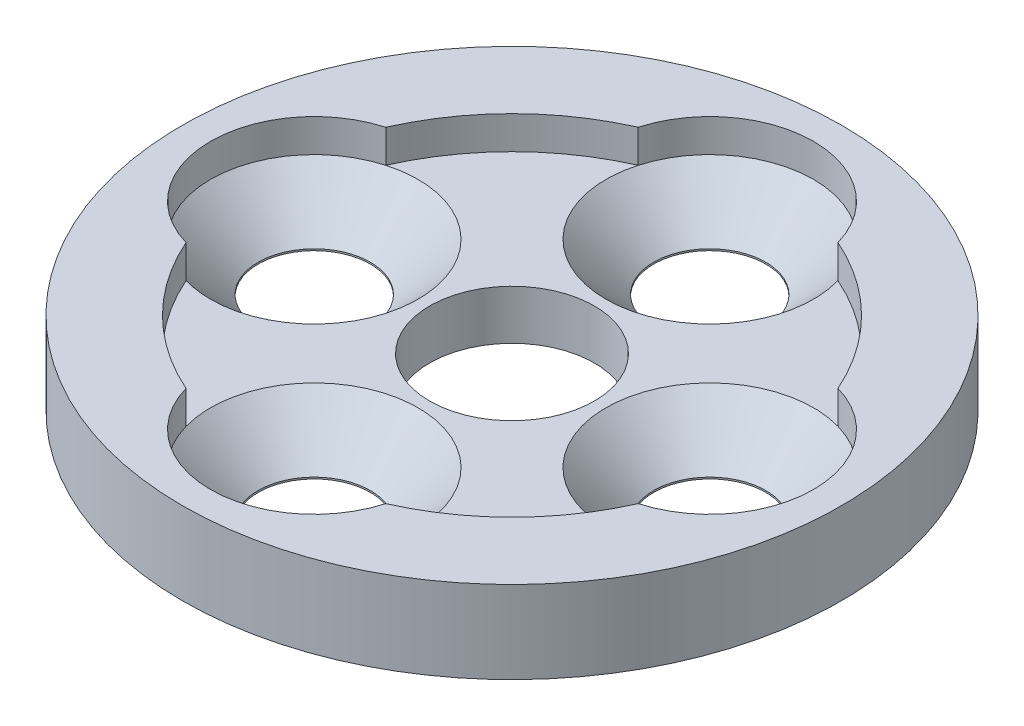
from build123d import *

# Parameters (mm, degrees)
SKETCH1_R                                    = 10
BOSS_EXTRUDE1_DEPTH                          = 1.5
SKETCH2_R                                    = 10
SKETCH2_R_2                                  = 7.5
BOSS_EXTRUDE2_DEPTH                          = 1
CSK_FOR_M3_COUNTERSUNK_FLAT_HEAD_SCR_2_COUNT = 2
CSK_FOR_M3_COUNTERSUNK_FLAT_HEAD_SCR_2_PITCH = 8.485281374
CSK_FOR_M3_COUNTERSUNK_FLAT_HEAD_SCR_3_COUNT = 2
CSK_FOR_M3_COUNTERSUNK_FLAT_HEAD_SCR_3_PITCH = 12
CSK_FOR_M3_COUNTERSUNK_FLAT_HEAD_SCR_4_COUNT = 2
CSK_FOR_M3_COUNTERSUNK_FLAT_HEAD_SCR_4_PITCH = 8.485281374
SKETCH5_R                                    = 3.15
CUT_EXTRUDE1_DEPTH                           = 21
SKETCH6_R                                    = 2.5
CUT_EXTRUDE2_DEPTH                           = 2
CUT_EXTRUDE2_DEPTH_BACK                      = 2.5


with BuildPart() as part:
    # Sketch1 → Boss-Extrude1 (new body)
    with BuildSketch(Plane(origin=(0, 0, 0), x_dir=(1, 0, 0), z_dir=(0, 1, 0))):
        Circle(SKETCH1_R)
    extrude(amount=BOSS_EXTRUDE1_DEPTH)

    # Sketch2 → Boss-Extrude2 (add)
    with BuildSketch(Plane(origin=(0, 1.5, 0), x_dir=(1, 0, 0), z_dir=(0, 1, 0))):
        Circle(SKETCH2_R)
        Circle(SKETCH2_R_2, mode=Mode.SUBTRACT)
    extrude(amount=BOSS_EXTRUDE2_DEPTH)

    # Sketch4 → CSK for M3 Countersunk Flat Head Screw1 (revolve, cut)
    with BuildSketch(Plane(origin=(-6, 1.5, 0), x_dir=(0, 0, 1), z_dir=(1, 0, 0))):
        Polygon((0, 0), (0, 1.5), (1.7, 1.5), (1.7, 1.45), (3.15, 0), align=None)
    csk_for_m3_countersunk_flat_head_screw1 = revolve(axis=Axis((-6, 7.85, 0), (0, -1, 0)), mode=Mode.SUBTRACT)

    # CSK for M3 Countersunk Flat Head Scr 2: CSK for M3 Countersunk Flat Head Screw1 ×2
    with Locations(*[Vector(0.707106781, 0, -0.707106781) * (i * CSK_FOR_M3_COUNTERSUNK_FLAT_HEAD_SCR_2_PITCH) for i in range(1, CSK_FOR_M3_COUNTERSUNK_FLAT_HEAD_SCR_2_COUNT)]):
        add(csk_for_m3_countersunk_flat_head_screw1, mode=Mode.SUBTRACT)

    # CSK for M3 Countersunk Flat Head Scr 3: CSK for M3 Countersunk Flat Head Screw1 ×2
    with Locations(*[(i * CSK_FOR_M3_COUNTERSUNK_FLAT_HEAD_SCR_3_PITCH, 0, 0) for i in range(1, CSK_FOR_M3_COUNTERSUNK_FLAT_HEAD_SCR_3_COUNT)]):
        add(csk_for_m3_countersunk_flat_head_screw1, mode=Mode.SUBTRACT)

    # CSK for M3 Countersunk Flat Head Scr 4: CSK for M3 Countersunk Flat Head Screw1 ×2
    with Locations(*[Vector(0.707106781, 0, 0.707106781) * (i * CSK_FOR_M3_COUNTERSUNK_FLAT_HEAD_SCR_4_PITCH) for i in range(1, CSK_FOR_M3_COUNTERSUNK_FLAT_HEAD_SCR_4_COUNT)]):
        add(csk_for_m3_countersunk_flat_head_screw1, mode=Mode.SUBTRACT)

    # Sketch5 → Cut-Extrude1 (cut)
    with BuildSketch(Plane(origin=(0, 1.5, 0), x_dir=(1, 0, 0), z_dir=(0, 1, 0))):
        with Locations((6, 0)):
            Circle(SKETCH5_R)
        with Locations((0, -6)):
            Circle(SKETCH5_R)
        with Locations((-6, 0)):
            Circle(SKETCH5_R)
        with Locations((0, 6)):
            Circle(SKETCH5_R)
    extrude(amount=CUT_EXTRUDE1_DEPTH, mode=Mode.SUBTRACT)

    # Sketch6 → Cut-Extrude2 (cut, two sides)
    with BuildSketch(Plane(origin=(0, 1.5, 0), x_dir=(1, 0, 0), z_dir=(0, 1, 0))) as cut_extrude2_sk:
        Circle(SKETCH6_R)
    extrude(amount=CUT_EXTRUDE2_DEPTH, mode=Mode.SUBTRACT)
    extrude(cut_extrude2_sk.sketch, amount=-CUT_EXTRUDE2_DEPTH_BACK, mode=Mode.SUBTRACT)


solid = part.part
